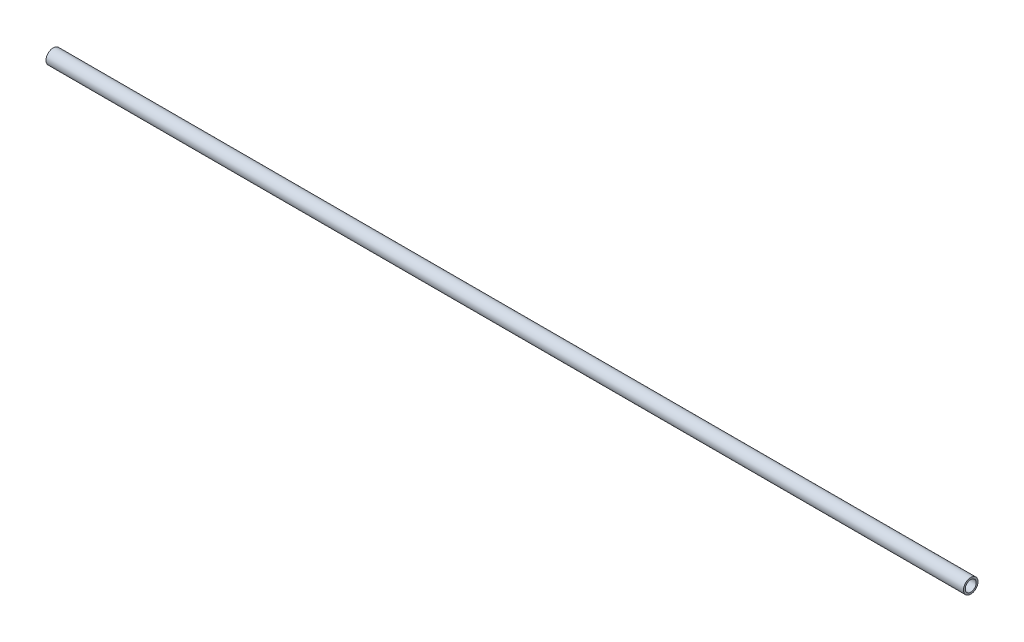
from build123d import *

# Parameters (mm, degrees)
SKETCH2_R           = 8
SKETCH2_R_2         = 6
BOSS_EXTRUDE1_DEPTH = 1016
SKETCH3_W           = 6.35
SKETCH3_H           = 95.207020631
CUT_EXTRUDE1_DEPTH  = 17


with BuildPart() as part:
    # Sketch2 → Boss-Extrude1 (new body)
    with BuildSketch(Plane(origin=(0, 0, 0), x_dir=(0, 0, -1), z_dir=(1, 0, 0))):
        Circle(SKETCH2_R)
        Circle(SKETCH2_R_2, mode=Mode.SUBTRACT)
    extrude(amount=BOSS_EXTRUDE1_DEPTH)

    # Sketch3 → Cut-Extrude1 (cut, through all)
    with BuildSketch(Plane(origin=(0, 8, 0), x_dir=(1, 0, 0), z_dir=(0, 1, 0))):
        with Locations((3.175, -2.072554833)):
            Rectangle(SKETCH3_W, SKETCH3_H)
    extrude(amount=-CUT_EXTRUDE1_DEPTH, mode=Mode.SUBTRACT)


solid = part.part
